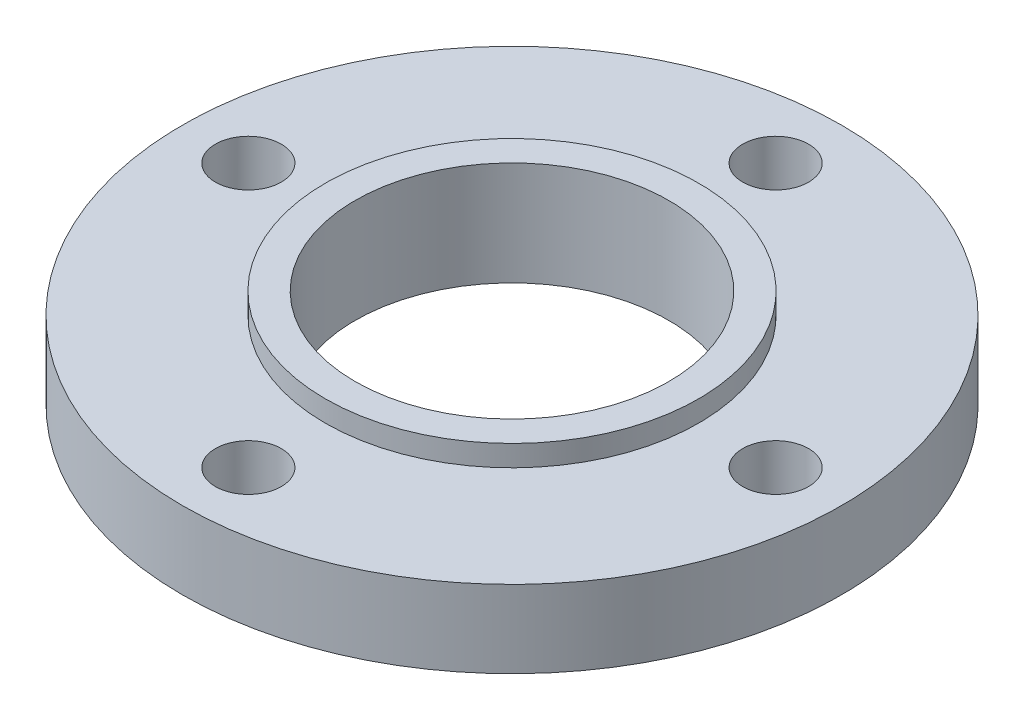
from build123d import *

# Parameters (mm, degrees)
SKETCH1_R               = 3.75
BOSS_EXTRUDE1_DEPTH     = 0.88
SKETCH2_R               = 2.125
BOSS_EXTRUDE2_DEPTH     = 1.12
SKETCH3_R               = 2.5
BOSS_EXTRUDE3_DEPTH     = 0.0625
SKETCH4_R               = 1.785
CUT_EXTRUDE1_DEPTH      = 3
CUT_EXTRUDE1_DEPTH_BACK = 1.0625
SKETCH7_R               = 0.375
CUT_EXTRUDE2_DEPTH      = 3.0625
CIRPATTERN1_COUNT       = 4
SCALE1_SCALE            = 25.4


with BuildPart() as part:
    # Sketch1 → Boss-Extrude1 (new body)
    with BuildSketch(Plane(origin=(0, 0, 0), x_dir=(1, 0, 0), z_dir=(0, 1, 0))):
        Circle(SKETCH1_R)
    extrude(amount=BOSS_EXTRUDE1_DEPTH)

    # Sketch2 → Boss-Extrude2 (add)
    with BuildSketch(Plane(origin=(0, 0, 0), x_dir=(1, 0, 0), z_dir=(0, 1, 0))):
        Circle(SKETCH2_R)
    extrude(amount=BOSS_EXTRUDE2_DEPTH)

    # Sketch3 → Boss-Extrude3 (add)
    with BuildSketch(Plane(origin=(0, 0, 0), x_dir=(1, 0, 0), z_dir=(0, 1, 0))):
        Circle(SKETCH3_R)
    extrude(amount=-BOSS_EXTRUDE3_DEPTH)

    # Sketch4 → Cut-Extrude1 (cut, two sides)
    with BuildSketch(Plane(origin=(0, 0, 0), x_dir=(1, 0, 0), z_dir=(0, 1, 0))) as cut_extrude1_sk:
        Circle(SKETCH4_R)
    extrude(amount=CUT_EXTRUDE1_DEPTH, mode=Mode.SUBTRACT)
    extrude(cut_extrude1_sk.sketch, amount=-CUT_EXTRUDE1_DEPTH_BACK, mode=Mode.SUBTRACT)

    # Sketch7 → Cut-Extrude2 (cut)
    with BuildSketch(Plane(origin=(0, 0, 0), x_dir=(1, 0, 0), z_dir=(0, 1, 0))):
        with Locations((0, 3)):
            Circle(SKETCH7_R)
    cut_extrude2 = extrude(amount=CUT_EXTRUDE2_DEPTH, mode=Mode.SUBTRACT)

    # CirPattern1: Cut-Extrude2 ×4 about axis
    cirpattern1_axis = Axis((0, 0, 0), (0, 1, 0))
    for i in range(1, CIRPATTERN1_COUNT):
        add(cut_extrude2.rotate(cirpattern1_axis, i * 360 / CIRPATTERN1_COUNT), mode=Mode.SUBTRACT)


with BuildPart() as part_1:
    # Scale1: scaled about (0, 0.449224649, 0)
    add(part.part.scale(SCALE1_SCALE).moved(Location((0, -10.961081436, 0))))


solid = part_1.part
